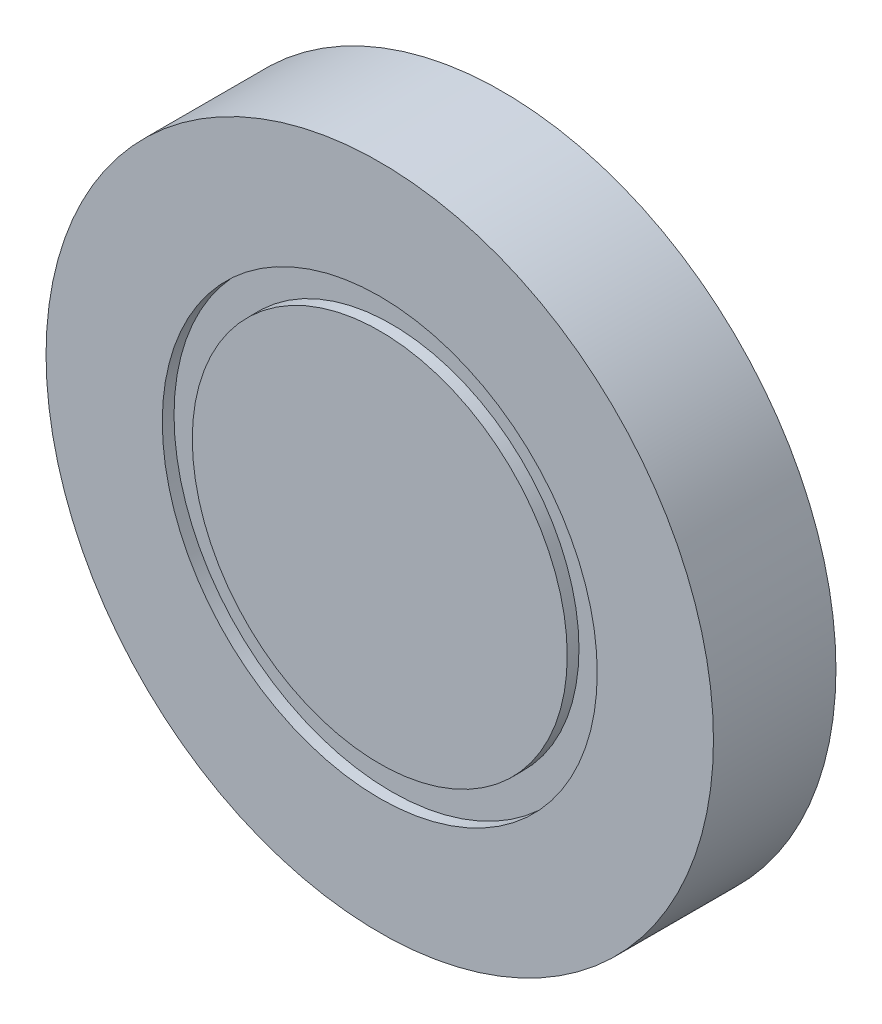
from build123d import *

# Parameters (mm, degrees)
SKETCH1_R           = 75
BOSS_EXTRUDE1_DEPTH = 49
SKETCH1_3_R         = 87
SKETCH1_3_R_2       = 75
BOSS_EXTRUDE2_DEPTH = 44.3
SKETCH1_4_R         = 133.5
SKETCH1_4_R_2       = 87
BOSS_EXTRUDE3_DEPTH = 49


with BuildPart() as part:
    # Sketch1 → Boss-Extrude1 (new body)
    with BuildSketch(Plane.XY):
        Circle(SKETCH1_R)
    extrude(amount=BOSS_EXTRUDE1_DEPTH)

    # Sketch1_3 → Boss-Extrude2 (add)
    with BuildSketch(Plane.XY):
        Circle(SKETCH1_3_R)
        Circle(SKETCH1_3_R_2, mode=Mode.SUBTRACT)
    extrude(amount=BOSS_EXTRUDE2_DEPTH)

    # Sketch1_4 → Boss-Extrude3 (add)
    with BuildSketch(Plane.XY):
        Circle(SKETCH1_4_R)
        Circle(SKETCH1_4_R_2, mode=Mode.SUBTRACT)
    extrude(amount=BOSS_EXTRUDE3_DEPTH)


solid = part.part
